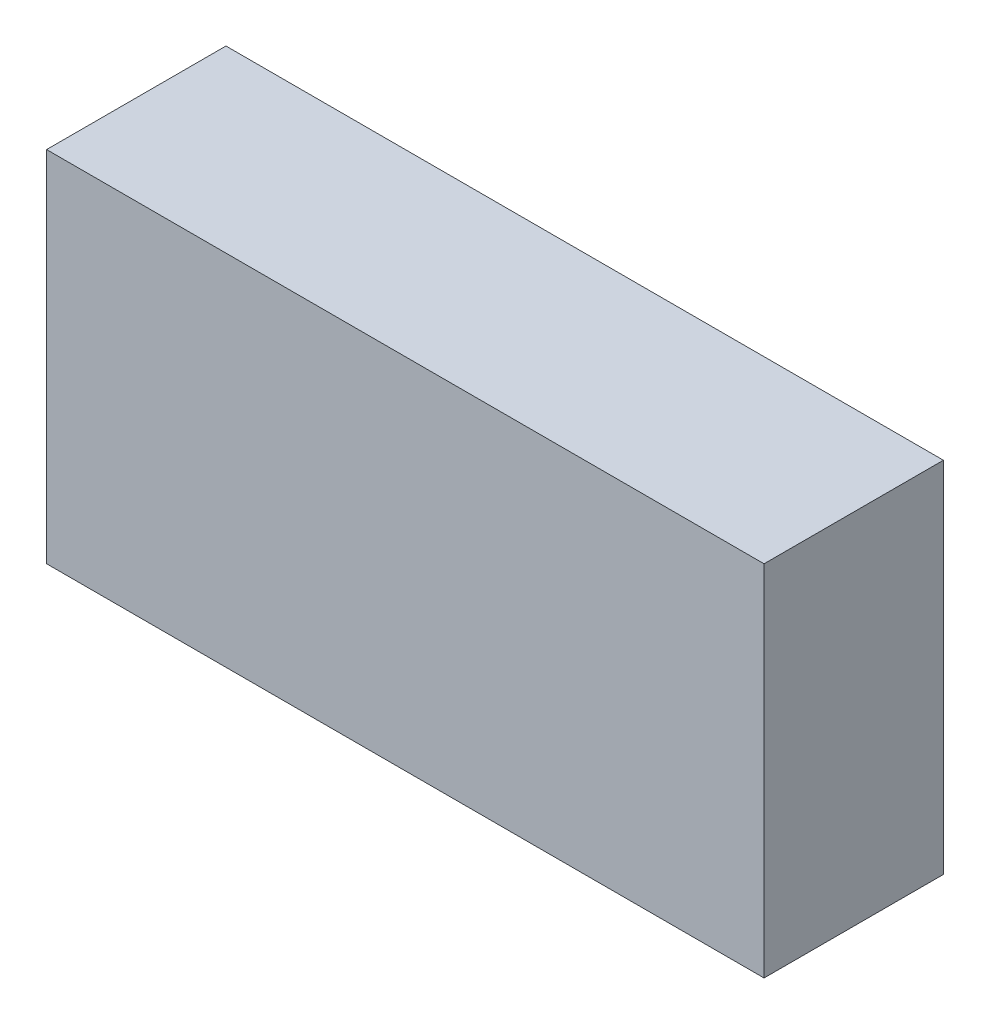
from build123d import *

# Parameters (mm, degrees)
SKETCH1_W           = 101.6
SKETCH1_H           = 25.4
BOSS_EXTRUDE1_DEPTH = 50.8


with BuildPart() as part:
    # Sketch1 → Boss-Extrude1 (new body)
    with BuildSketch(Plane(origin=(0, 0, 0), x_dir=(1, 0, 0), z_dir=(0, 1, 0))):
        with Locations((8.649017486, 54.518747445)):
            Rectangle(SKETCH1_W, SKETCH1_H)
    extrude(amount=BOSS_EXTRUDE1_DEPTH)


solid = part.part
